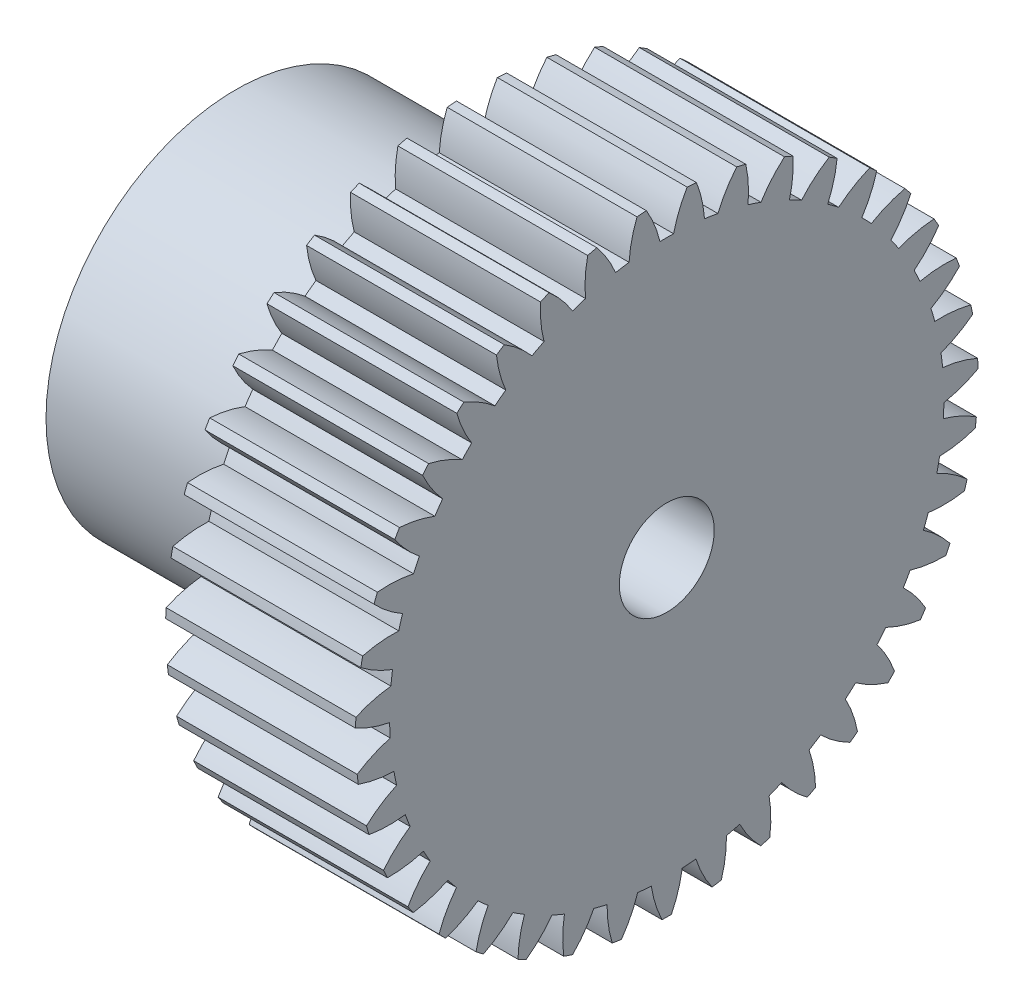
from build123d import *

# Parameters (mm, degrees)
BASPROSKE_W        = 10
BASPROSKE_H        = 16.4
TOOTHCUT_DEPTH     = 26.257078216
TEETHCUTS_COUNT    = 39
TEETHCUTS_ANGLE    = 350.769230769
HUBNEAONESKE_R     = 10
HUBNEARONE_DEPTH   = 12.7000508
BORE_DEPTH         = 27.439360462
BORE_DEPTH_BACK    = 27.439360462
BORSKE_R           = 2.5
SKETCH1_R          = 2.65
SKETCH1_R_2        = 1.6
CUT_EXTRUDE1_DEPTH = 5
CUT_EXTRUDE2_DEPTH = 10


with BuildPart() as part:
    # BasProSke → Base-Revolve (revolve)
    with BuildSketch(Plane(origin=(0, 0, 0), x_dir=(1, 0, 0), z_dir=(0, 1, 0))):
        with Locations((5, 8.2)):
            Rectangle(BASPROSKE_W, BASPROSKE_H)
    revolve(axis=Axis((-10, 0, 0), (1, 0, 0)))

    # TooCutSke → ToothCut (cut, through all)
    with BuildSketch(Plane(origin=(0, 0, 0), x_dir=(0, 0, -1), z_dir=(1, 0, 0))):
        with BuildLine():
            ThreePointArc((0.35934894, 14.59457671), (0, 14.599), (-0.35934894, 14.59457671))
            ThreePointArc((-0.35934894, 14.59457671), (-0.653910463, 15.520403912), (-1.088613769, 16.389285684))
            ThreePointArc((-1.088613769, 16.389285684), (0, 16.4254), (1.088613769, 16.389285684))
            ThreePointArc((1.088613769, 16.389285684), (0.653910463, 15.520403912), (0.35934894, 14.59457671))
        make_face()
    toothcut = extrude(amount=TOOTHCUT_DEPTH, mode=Mode.SUBTRACT)

    # TeethCuts: ToothCut ×39 about axis
    teethcuts_axis = Axis((-10, 0, 0), (1, 0, 0))
    for i in range(1, TEETHCUTS_COUNT):
        add(toothcut.rotate(teethcuts_axis, i * TEETHCUTS_ANGLE / (TEETHCUTS_COUNT - 1)), mode=Mode.SUBTRACT)

    # HubNeaOneSke → HubNearOne (add)
    with BuildSketch(Plane.ZY):
        Circle(HUBNEAONESKE_R)
    extrude(amount=HUBNEARONE_DEPTH)

    # BorSke → Bore (cut, two sides: drawn at the far end of the back side and taken through both)
    with BuildSketch(Plane(origin=(0, 0, 0), x_dir=(0, 0, -1), z_dir=(1, 0, 0)).offset(-BORE_DEPTH_BACK)):
        Circle(BORSKE_R)
    extrude(amount=BORE_DEPTH + BORE_DEPTH_BACK, mode=Mode.SUBTRACT)

    # Sketch1 → Cut-Extrude1 (cut)
    with BuildSketch(Plane(origin=(0, 0, -10), x_dir=(-1, 0, 0), z_dir=(0, 0, -1))):
        with Locations((6.3500254, 0)):
            Circle(SKETCH1_R)
        with Locations((6.3500254, 0)):
            Circle(SKETCH1_R_2, mode=Mode.SUBTRACT)
    extrude(amount=-CUT_EXTRUDE1_DEPTH, mode=Mode.SUBTRACT)

    # Sketch1_2 → Cut-Extrude2 (cut)
    with BuildSketch(Plane(origin=(0, 0, -10), x_dir=(-1, 0, 0), z_dir=(0, 0, -1))):
        with BuildLine():
            ThreePointArc((7.9500254, 0), (5.21865455, 1.13137085), (6.3500254, -1.6))
            ThreePointArc((6.3500254, -1.6), (7.48139625, -1.13137085), (7.9500254, 0))
        make_face()
    extrude(amount=-CUT_EXTRUDE2_DEPTH, mode=Mode.SUBTRACT)


solid = part.part
